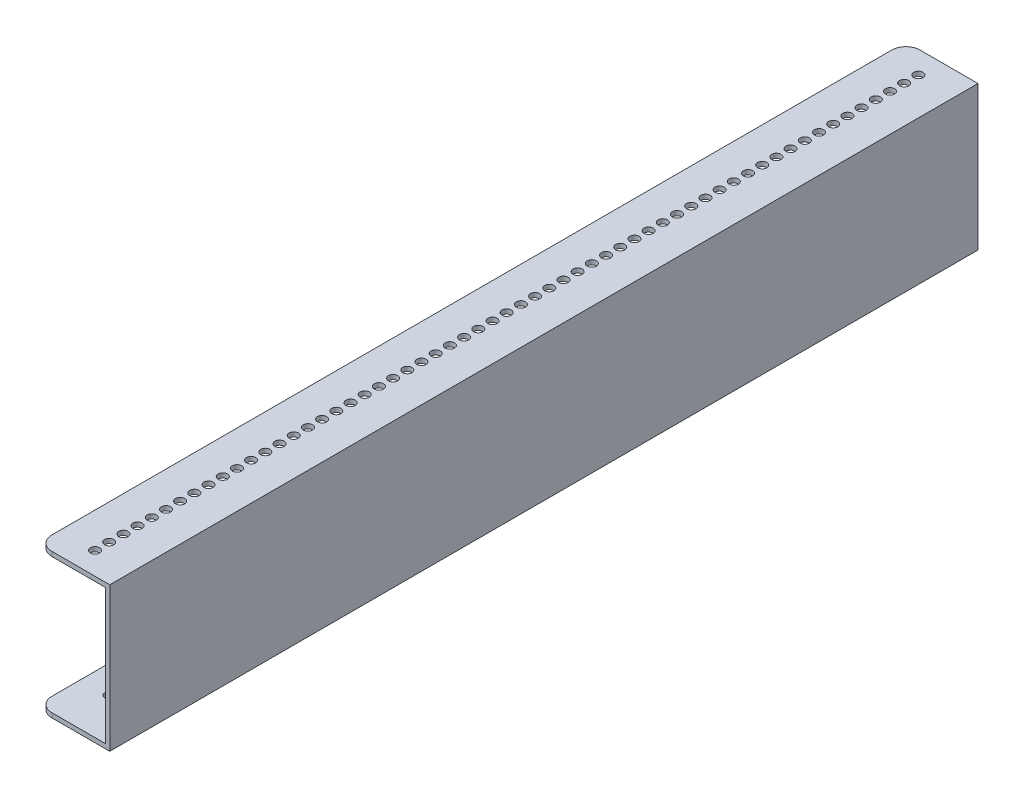
from build123d import *

# Parameters (mm, degrees)
ALUM_C_CHNL_LONGBOSS_EXTRUDE2_DEPTH      = 305.8
ALUM_C_CHNL_LONGBOSS_EXTRUDE2_DEPTH_BACK = 305.8
FILLET1_R                                = 10
SKETCH7_R                                = 3.25
CUT_EXTRUDE4_DEPTH                       = 20
LPATTERN2_COUNT                          = 30
LPATTERN2_PITCH                          = 10
LPATTERN1_COUNT                          = 30
LPATTERN1_PITCH                          = 10
SKETCH10_R                               = 3.25
CUT_EXTRUDE8_DEPTH                       = 3.175


with BuildPart() as part:
    # Sketch2 → Alum C chnl LONGBoss-Extrude2 (new body, two sides)
    with BuildSketch(Plane.XY) as alum_c_chnl_longboss_extrude2_sk:
        Polygon((-304.8, 12.7), (-304.8, 15.875), (-257.175, 15.875), (-257.175, 111.125), (-304.8, 111.125), (-304.8, 114.3), (-254, 114.3), (-254, 12.7), align=None)
    extrude(amount=ALUM_C_CHNL_LONGBOSS_EXTRUDE2_DEPTH)
    extrude(alum_c_chnl_longboss_extrude2_sk.sketch, amount=-ALUM_C_CHNL_LONGBOSS_EXTRUDE2_DEPTH_BACK)

    # Fillet1
    fillet1_edges = [part.edges().sort_by_distance(p)[0] for p in [
        (-304.8, 112.7125, -305.8),
        (-304.8, 112.7125, 305.8),
        (-304.8, 14.2875, 305.8),
        (-304.8, 14.2875, -305.8),
    ]]
    fillet(fillet1_edges, radius=FILLET1_R)

    # Sketch7 → Cut-Extrude4 (cut)
    with BuildSketch(Plane(origin=(0, 114.3, 0), x_dir=(1, 0, 0), z_dir=(0, 1, 0))):
        with Locations((-280.2, 0)):
            Circle(SKETCH7_R)
    cut_extrude4 = extrude(amount=-CUT_EXTRUDE4_DEPTH, mode=Mode.SUBTRACT)

    # LPattern2: Cut-Extrude4 ×30
    with Locations(*[(0, 0, -i * LPATTERN2_PITCH) for i in range(1, LPATTERN2_COUNT)]):
        add(cut_extrude4, mode=Mode.SUBTRACT)

    # LPattern1: Cut-Extrude4 ×30
    with Locations(*[(0, 0, i * LPATTERN1_PITCH) for i in range(1, LPATTERN1_COUNT)]):
        add(cut_extrude4, mode=Mode.SUBTRACT)

    # Sketch10 → Cut-Extrude8 (cut)
    with BuildSketch(Plane(origin=(0, 15.875, 0), x_dir=(1, 0, 0), z_dir=(0, 1, 0))):
        with Locations((-285, 275)):
            Circle(SKETCH10_R)
        with Locations((-285, 0)):
            Circle(SKETCH10_R)
        with Locations((-285, -275)):
            Circle(SKETCH10_R)
    extrude(amount=-CUT_EXTRUDE8_DEPTH, mode=Mode.SUBTRACT)


solid = part.part
